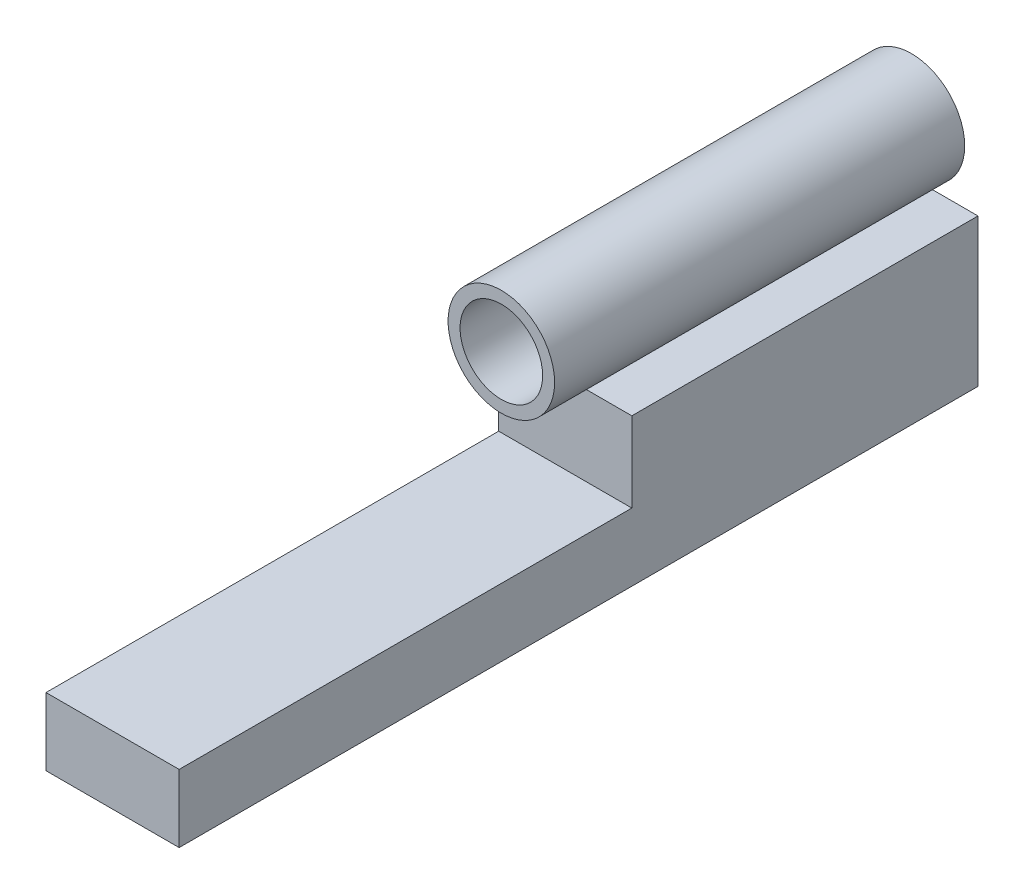
from build123d import *

# Parameters (mm, degrees)
SKETCH1_R           = 7.75
SKETCH1_R_2         = 2.5
BOSS_EXTRUDE1_DEPTH = 2.5
SKETCH1_3_R         = 10
SKETCH1_3_R_2       = 7.75
BOSS_EXTRUDE2_DEPTH = 77
SKETCH1_4_W         = 25
SKETCH1_4_H         = 15
BOSS_EXTRUDE3_DEPTH = 65
SKETCH1_5_W         = 25
SKETCH1_5_H         = 12.716539713
BOSS_EXTRUDE4_DEPTH = 150


with BuildPart() as part:
    # Sketch1 → Boss-Extrude1 (new body)
    with BuildSketch(Plane.XY):
        with Locations((0, 10.160427276)):
            Circle(SKETCH1_R)
        with Locations((0, 10.160427276)):
            Circle(SKETCH1_R_2, mode=Mode.SUBTRACT)
    extrude(amount=BOSS_EXTRUDE1_DEPTH)

    # Sketch1_3 → Boss-Extrude2 (add)
    with BuildSketch(Plane.XY):
        with Locations((0, 10.160427276)):
            Circle(SKETCH1_3_R)
        with Locations((0, 10.160427276)):
            Circle(SKETCH1_3_R_2, mode=Mode.SUBTRACT)
    extrude(amount=BOSS_EXTRUDE2_DEPTH)


with BuildPart() as body_2:
    # Sketch1_4 → Boss-Extrude3 (new body)
    with BuildSketch(Plane.XY):
        with Locations((0, -7.5)):
            Rectangle(SKETCH1_4_W, SKETCH1_4_H)
    extrude(amount=BOSS_EXTRUDE3_DEPTH)

    # Sketch1_5 → Boss-Extrude4 (add)
    with BuildSketch(Plane.XY):
        with Locations((0, -21.358269857)):
            Rectangle(SKETCH1_5_W, SKETCH1_5_H)
    extrude(amount=BOSS_EXTRUDE4_DEPTH)


solid = Compound([part.part, body_2.part])
